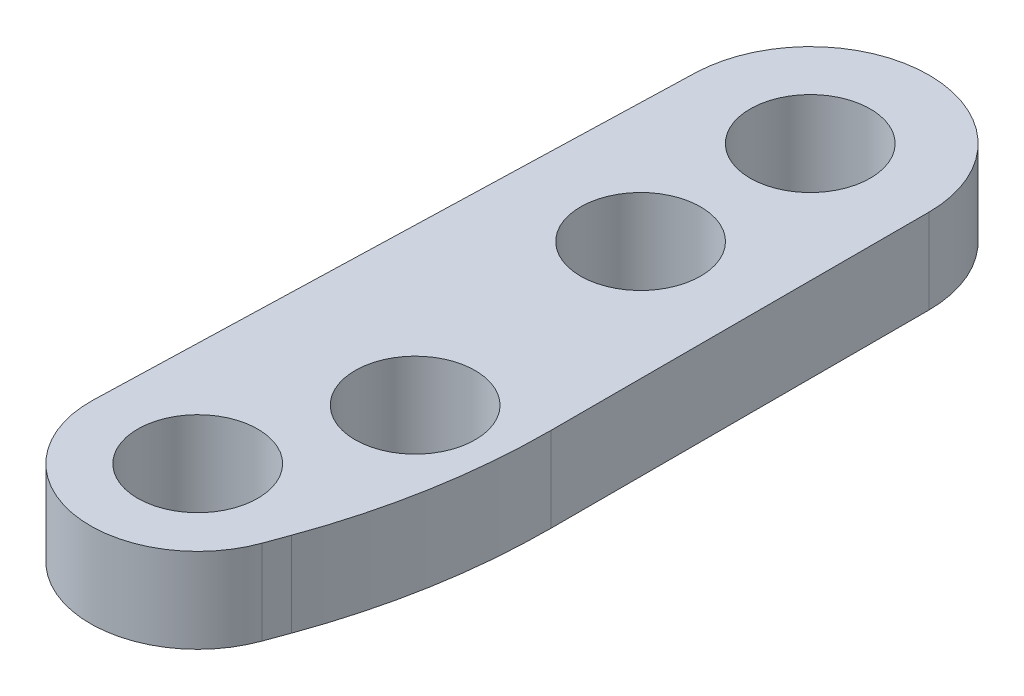
from build123d import *

# Parameters (mm, degrees)
BOSS_EXTRUDE3_DEPTH       = 3.175
F_8_CLEARANCE_HOLE1_D     = 4.4958
F_8_CLEARANCE_HOLE1_DEPTH = 41.402
F_8_CLEARANCE_HOLE1_TIP   = 1.350674586
F_8_CLEARANCE_HOLE2_D     = 4.4958
F_8_CLEARANCE_HOLE2_DEPTH = 41.402
F_8_CLEARANCE_HOLE2_TIP   = 1.350674586


with BuildPart() as part:
    # Sketch7 → Boss-Extrude3 (new body)
    with BuildSketch(Plane(origin=(0, 0, 0), x_dir=(1, 0, 0), z_dir=(0, 1, 0))):
        with BuildLine():
            Line((5.530913955, 21.842048142), (5.530913955, 7.688957681))
            ThreePointArc((5.530913955, 7.688957681), (5.164609953, 3.502083783), (4.07682791, -0.55757407))
            Line((4.07682791, -0.55757407), (3.77913049, -1.37549101))
            ThreePointArc((3.77913049, -1.37549101), (-0.758308624, -3.949527922), (-4.019818623, 0.121905765))
            Line((-4.019818623, 0.121905765), (-3.35704347, 21.976786093))
            ThreePointArc((-3.35704347, 21.976786093), (1.153290671, 26.286537469), (5.530913955, 21.842048142))
        make_face()
    extrude(amount=BOSS_EXTRUDE3_DEPTH)

    # #8 Clearance Hole1
    with Locations(Plane(origin=(0, 3.175, 0), x_dir=(1, 0, 0), z_dir=(0, 1, 0))):
        with Locations((2.17182791, 5.967048142), (0, 0)):
            Hole(F_8_CLEARANCE_HOLE1_D / 2, depth=F_8_CLEARANCE_HOLE1_DEPTH)
            with Locations((0, 0, -(F_8_CLEARANCE_HOLE1_DEPTH + F_8_CLEARANCE_HOLE1_TIP / 2))):  # 118° drill point
                Cone(0, F_8_CLEARANCE_HOLE1_D / 2, F_8_CLEARANCE_HOLE1_TIP, mode=Mode.SUBTRACT)

    # #8 Clearance Hole2
    with Locations(Plane(origin=(0, 3.175, 0), x_dir=(1, 0, 0), z_dir=(0, 1, 0))):
        with Locations((1.085913955, 21.842048142), (1.085913955, 15.492048142)):
            Hole(F_8_CLEARANCE_HOLE2_D / 2, depth=F_8_CLEARANCE_HOLE2_DEPTH)
            with Locations((0, 0, -(F_8_CLEARANCE_HOLE2_DEPTH + F_8_CLEARANCE_HOLE2_TIP / 2))):  # 118° drill point
                Cone(0, F_8_CLEARANCE_HOLE2_D / 2, F_8_CLEARANCE_HOLE2_TIP, mode=Mode.SUBTRACT)


solid = part.part
